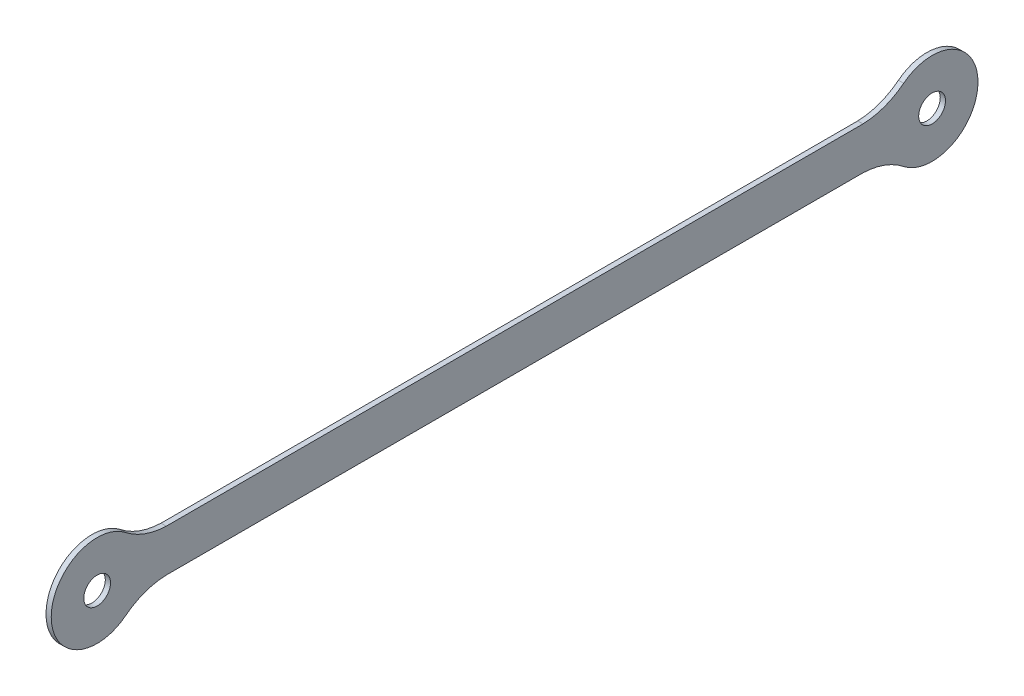
from build123d import *

# Parameters (mm, degrees)
SKETCH_2_R      = 3.85
EXTRUDE_1_DEPTH = 1.5


with BuildPart() as part:
    # 草圖2 → 填料-伸長1 (new body)
    with BuildSketch(Plane(origin=(0, 0, 0), x_dir=(0, 0, -1), z_dir=(1, 0, 0))):
        with BuildLine():
            Line((-86.216124971, 6.090280685), (114.038610046, 6.090280685))
            ThreePointArc((114.038610046, 6.090280685), (120.229892502, 7.285685691), (125.736176674, 10.35843791))
            ThreePointArc((125.736176674, 10.35843791), (147.107034966, 0), (125.736176674, -10.35843791))
            ThreePointArc((125.736176674, -10.35843791), (120.229892502, -7.285685691), (114.038610046, -6.090280685))
            Line((114.038610046, -6.090280685), (-86.216124971, -6.090280685))
            ThreePointArc((-86.216124971, -6.090280685), (-92.407407427, -7.285685691), (-97.913691598, -10.35843791))
            ThreePointArc((-97.913691598, -10.35843791), (-119.284549891, 0), (-97.913691598, 10.35843791))
            ThreePointArc((-97.913691598, 10.35843791), (-92.407407427, 7.285685691), (-86.216124971, 6.090280685))
        make_face()
        with Locations((133.911242538, 0)):
            Circle(SKETCH_2_R, mode=Mode.SUBTRACT)
        with Locations((-106.088757462, 0)):
            Circle(SKETCH_2_R, mode=Mode.SUBTRACT)
    extrude(amount=EXTRUDE_1_DEPTH)


solid = part.part
